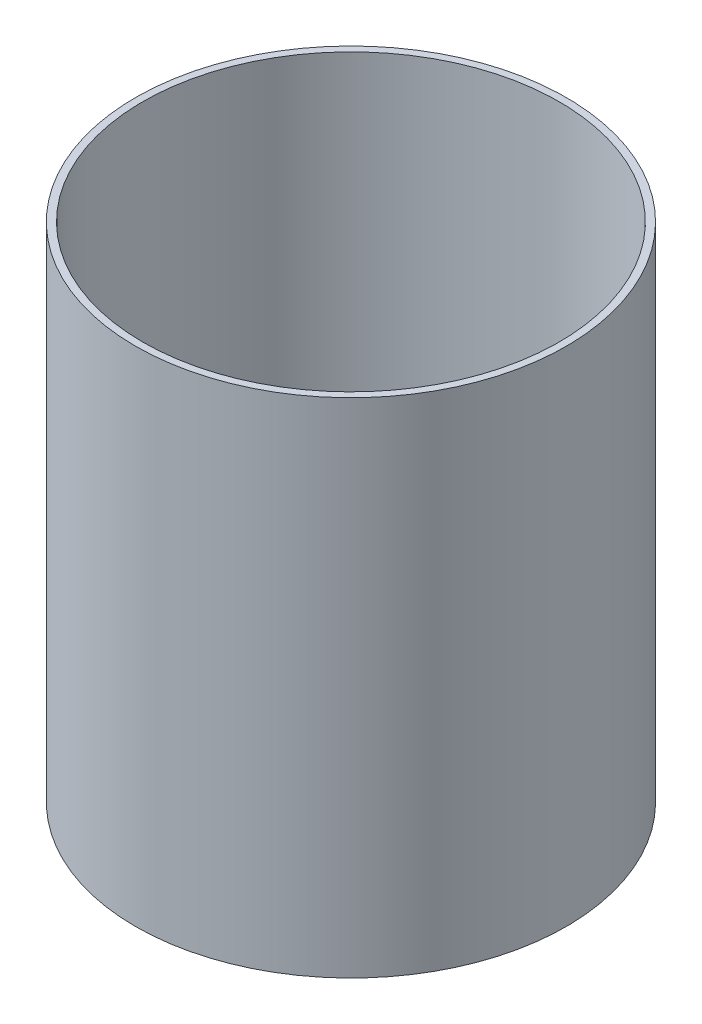
from build123d import *

# Parameters (mm, degrees)
SKETCH1_R           = 38.1
SKETCH1_R_2         = 36.83
BOSS_EXTRUDE1_DEPTH = 88.9


with BuildPart() as part:
    # Sketch1 → Boss-Extrude1 (new body)
    with BuildSketch(Plane(origin=(0, 0, 0), x_dir=(1, 0, 0), z_dir=(0, 1, 0))):
        Circle(SKETCH1_R)
        Circle(SKETCH1_R_2, mode=Mode.SUBTRACT)
    extrude(amount=BOSS_EXTRUDE1_DEPTH)


solid = part.part
